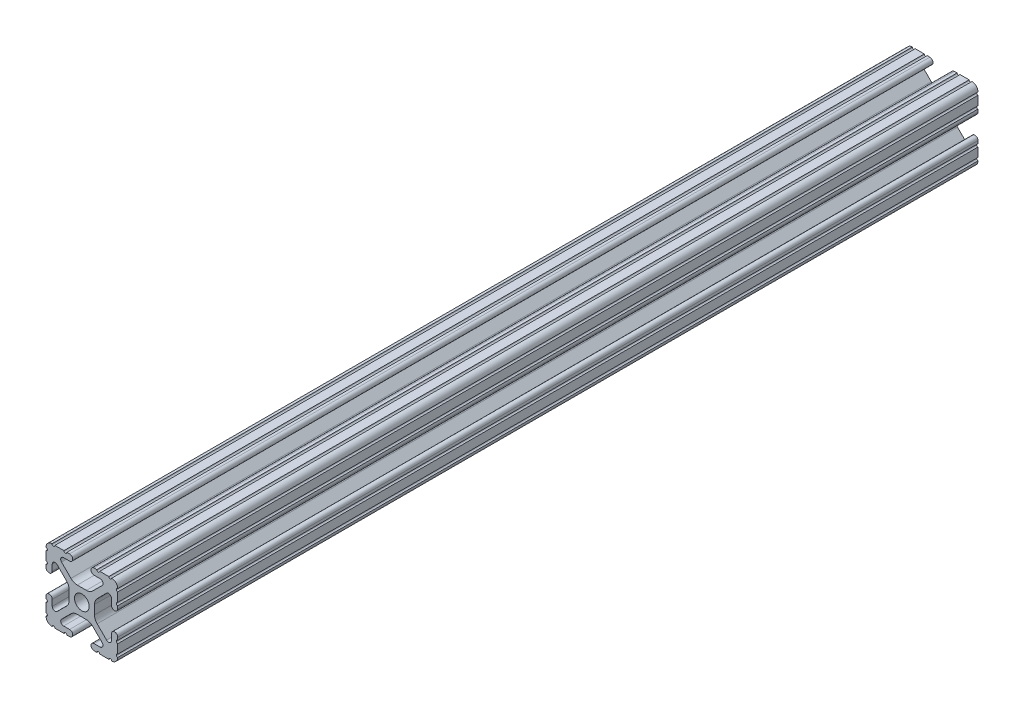
from build123d import *

# Parameters (mm, degrees)
SKETCH1_R           = 2.6035
BOSS_EXTRUDE1_DEPTH = 1270
SKETCH6_W           = 122.666969327
SKETCH6_H           = 109.347800906
CUT_EXTRUDE1_DEPTH  = 572.5
SKETCH7_W           = 38.999416314
SKETCH7_H           = 31.386968174
CUT_EXTRUDE2_DEPTH  = 393.7


with BuildPart() as part:
    # Sketch1 → Boss-Extrude1 (new body)
    with BuildSketch(Plane(origin=(0, 0, -1270), x_dir=(-1, 0, 0), z_dir=(0, 0, -1))):
        with BuildLine():
            Line((12.7, -9.5504), (12.7, -6.3330836))
            ThreePointArc((12.7, -6.3330836), (12.192, -5.8250836), (12.7, -5.3170836))
            Line((12.7, -5.3170836), (12.7, -4.3434))
            ThreePointArc((12.7, -4.3434), (11.5951, -3.2385), (10.4902, -4.3434))
            Line((10.4902, -4.3434), (10.4902, -6.474794456))
            ThreePointArc((10.4902, -6.474794456), (9.863006367, -7.413456061), (8.75577951, -7.193214945))
            Line((8.75577951, -7.193214945), (5.42573597, -3.863171405))
            ThreePointArc((5.42573597, -3.863171405), (4.737482484, -2.833127272), (4.4958, -1.618107374))
            Line((4.4958, -1.618107374), (4.4958, 1.618107374))
            ThreePointArc((4.4958, 1.618107374), (4.737482484, 2.833127272), (5.42573597, 3.863171405))
            Line((5.42573597, 3.863171405), (8.75577951, 7.193214945))
            ThreePointArc((8.75577951, 7.193214945), (9.863006367, 7.413456061), (10.4902, 6.474794456))
            Line((10.4902, 6.474794456), (10.4902, 4.343399971))
            ThreePointArc((10.4902, 4.343399971), (11.5951, 3.238499971), (12.7, 4.343399971))
            Line((12.7, 4.343399971), (12.7, 5.3170836))
            ThreePointArc((12.7, 5.3170836), (12.192, 5.8250836), (12.7, 6.3330836))
            Line((12.7, 6.3330836), (12.7, 9.5504))
            ThreePointArc((12.7, 9.5504), (12.192000006, 10.058323491), (12.699846982, 10.566399977))
            ThreePointArc((12.699846982, 10.566399977), (12.082522516, 12.082522516), (10.566399977, 12.699846982))
            ThreePointArc((10.566399977, 12.699846982), (10.058323491, 12.192000006), (9.5504, 12.7))
            Line((9.5504, 12.7), (6.3330836, 12.7))
            ThreePointArc((6.3330836, 12.7), (5.8250836, 12.192), (5.3170836, 12.7))
            Line((5.3170836, 12.7), (4.3434, 12.7))
            ThreePointArc((4.3434, 12.7), (3.2385, 11.5951), (4.3434, 10.4902))
            Line((4.3434, 10.4902), (6.474794456, 10.4902))
            ThreePointArc((6.474794456, 10.4902), (7.413456061, 9.863006367), (7.193214945, 8.75577951))
            Line((7.193214945, 8.75577951), (3.863171405, 5.42573597))
            ThreePointArc((3.863171405, 5.42573597), (2.833127272, 4.737482484), (1.618107374, 4.4958))
            Line((1.618107374, 4.4958), (-1.618107374, 4.4958))
            ThreePointArc((-1.618107374, 4.4958), (-2.833127272, 4.737482484), (-3.863171405, 5.42573597))
            Line((-3.863171405, 5.42573597), (-7.193214945, 8.75577951))
            ThreePointArc((-7.193214945, 8.75577951), (-7.413456061, 9.863006367), (-6.474794456, 10.4902))
            Line((-6.474794456, 10.4902), (-4.343399971, 10.4902))
            ThreePointArc((-4.343399971, 10.4902), (-3.238499971, 11.5951), (-4.343399971, 12.7))
            Line((-4.343399971, 12.7), (-5.3170836, 12.7))
            ThreePointArc((-5.3170836, 12.7), (-5.8250836, 12.192), (-6.3330836, 12.7))
            Line((-6.3330836, 12.7), (-9.5504, 12.7))
            ThreePointArc((-9.5504, 12.7), (-10.058323491, 12.192000006), (-10.566399977, 12.699846982))
            ThreePointArc((-10.566399977, 12.699846982), (-12.082522516, 12.082522516), (-12.699846982, 10.566399977))
            ThreePointArc((-12.699846982, 10.566399977), (-12.192000006, 10.058323491), (-12.7, 9.5504))
            Line((-12.7, 9.5504), (-12.7, 6.3330836))
            ThreePointArc((-12.7, 6.3330836), (-12.192, 5.8250836), (-12.7, 5.3170836))
            Line((-12.7, 5.3170836), (-12.7, 4.3434))
            ThreePointArc((-12.7, 4.3434), (-11.5951, 3.2385), (-10.4902, 4.3434))
            Line((-10.4902, 4.3434), (-10.4902, 6.474794456))
            ThreePointArc((-10.4902, 6.474794456), (-9.863006367, 7.413456061), (-8.75577951, 7.193214945))
            Line((-8.75577951, 7.193214945), (-5.42573597, 3.863171405))
            ThreePointArc((-5.42573597, 3.863171405), (-4.737482484, 2.833127272), (-4.4958, 1.618107374))
            Line((-4.4958, 1.618107374), (-4.4958, -1.618107374))
            ThreePointArc((-4.4958, -1.618107374), (-4.737482484, -2.833127272), (-5.42573597, -3.863171405))
            Line((-5.42573597, -3.863171405), (-8.75577951, -7.193214945))
            ThreePointArc((-8.75577951, -7.193214945), (-9.863006367, -7.413456061), (-10.4902, -6.474794456))
            Line((-10.4902, -6.474794456), (-10.4902, -4.343399971))
            ThreePointArc((-10.4902, -4.343399971), (-11.5951, -3.238499971), (-12.7, -4.343399971))
            Line((-12.7, -4.343399971), (-12.7, -5.3170836))
            ThreePointArc((-12.7, -5.3170836), (-12.192, -5.8250836), (-12.7, -6.3330836))
            Line((-12.7, -6.3330836), (-12.7, -9.5504))
            ThreePointArc((-12.7, -9.5504), (-12.192000006, -10.058323491), (-12.699846982, -10.566399977))
            ThreePointArc((-12.699846982, -10.566399977), (-12.082522516, -12.082522516), (-10.566399977, -12.699846982))
            ThreePointArc((-10.566399977, -12.699846982), (-10.058323491, -12.192000006), (-9.5504, -12.7))
            Line((-9.5504, -12.7), (-6.3330836, -12.7))
            ThreePointArc((-6.3330836, -12.7), (-5.8250836, -12.192), (-5.3170836, -12.7))
            Line((-5.3170836, -12.7), (-4.3434, -12.7))
            ThreePointArc((-4.3434, -12.7), (-3.2385, -11.5951), (-4.3434, -10.4902))
            Line((-4.3434, -10.4902), (-6.474794456, -10.4902))
            ThreePointArc((-6.474794456, -10.4902), (-7.413456061, -9.863006367), (-7.193214945, -8.75577951))
            Line((-7.193214945, -8.75577951), (-3.863171405, -5.42573597))
            ThreePointArc((-3.863171405, -5.42573597), (-2.833127272, -4.737482484), (-1.618107374, -4.4958))
            Line((-1.618107374, -4.4958), (1.618107374, -4.4958))
            ThreePointArc((1.618107374, -4.4958), (2.833127272, -4.737482484), (3.863171405, -5.42573597))
            Line((3.863171405, -5.42573597), (7.193214945, -8.75577951))
            ThreePointArc((7.193214945, -8.75577951), (7.413456061, -9.863006367), (6.474794456, -10.4902))
            Line((6.474794456, -10.4902), (4.343399971, -10.4902))
            ThreePointArc((4.343399971, -10.4902), (3.238499971, -11.5951), (4.343399971, -12.7))
            Line((4.343399971, -12.7), (5.3170836, -12.7))
            ThreePointArc((5.3170836, -12.7), (5.8250836, -12.192), (6.3330836, -12.7))
            Line((6.3330836, -12.7), (9.5504, -12.7))
            ThreePointArc((9.5504, -12.7), (10.058323491, -12.192000006), (10.566399977, -12.699846982))
            ThreePointArc((10.566399977, -12.699846982), (12.082522516, -12.082522516), (12.699846982, -10.566399977))
            ThreePointArc((12.699846982, -10.566399977), (12.192000006, -10.058323491), (12.7, -9.5504))
        make_face()
        Circle(SKETCH1_R, mode=Mode.SUBTRACT)
    extrude(amount=-BOSS_EXTRUDE1_DEPTH)

    # Sketch6 → Cut-Extrude1 (cut, through all)
    with BuildSketch(Plane(origin=(0, 0, -698.5), x_dir=(-1, 0, 0), z_dir=(0, 0, -1))):
        with Locations((17.668938213, -20.549718265)):
            Rectangle(SKETCH6_W, SKETCH6_H)
    extrude(amount=CUT_EXTRUDE1_DEPTH, mode=Mode.SUBTRACT)

    # Sketch7 → Cut-Extrude2 (cut)
    with BuildSketch(Plane(origin=(0, 0, -698.5), x_dir=(-1, 0, 0), z_dir=(0, 0, -1))):
        Rectangle(SKETCH7_W, SKETCH7_H)
    extrude(amount=-CUT_EXTRUDE2_DEPTH, mode=Mode.SUBTRACT)


solid = part.part
